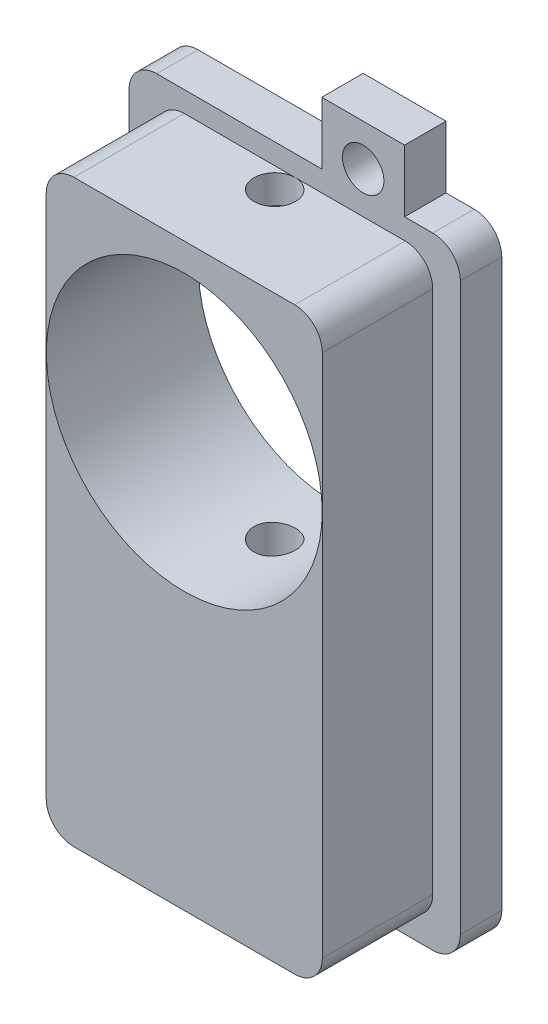
from build123d import *

# Parameters (mm, degrees)
SKETCH1_R           = 1.5
BOSS_EXTRUDE1_DEPTH = 3
FILLET1_R           = 2
SKETCH3_W           = 20
SKETCH3_H           = 42
BOSS_EXTRUDE2_DEPTH = 8
FILLET2_R           = 2
SKETCH4_R           = 9.99
CUT_EXTRUDE1_DEPTH  = 12
SKETCH5_R           = 1.5
CUT_EXTRUDE2_DEPTH  = 49


with BuildPart() as part:
    # Sketch1 → Boss-Extrude1 (new body)
    with BuildSketch(Plane.XY):
        Polygon((12, 22.5), (7.96, 22.5), (7.96, 27), (1.96, 27), (1.96, 22.5), (-12, 22.5), (-12, -22.5), (-7.96, -22.5), (-7.96, -27), (-1.96, -27), (-1.96, -22.5), (12, -22.5), align=None)
        with Locations((4.96, 24)):
            Circle(SKETCH1_R, mode=Mode.SUBTRACT)
        with Locations((-4.96, -24)):
            Circle(SKETCH1_R, mode=Mode.SUBTRACT)
    extrude(amount=BOSS_EXTRUDE1_DEPTH)

    # Fillet1
    fillet1_edges = [part.edges().sort_by_distance(p)[0] for p in [
        (-12, 22.5, 1.5),
        (12, 22.5, 1.5),
        (12, -22.5, 1.5),
        (-12, -22.5, 1.5),
    ]]
    fillet(fillet1_edges, radius=FILLET1_R)

    # Sketch3 → Boss-Extrude2 (add)
    with BuildSketch(Plane.XY.offset(3)):
        Rectangle(SKETCH3_W, SKETCH3_H)
    extrude(amount=BOSS_EXTRUDE2_DEPTH)

    # Fillet2
    fillet2_edges = [part.edges().sort_by_distance(p)[0] for p in [
        (-10, 21, 7),
        (-10, -21, 7),
        (10, -21, 7),
        (10, 21, 7),
    ]]
    fillet(fillet2_edges, radius=FILLET2_R)

    # Sketch4 → Cut-Extrude1 (cut, through all)
    with BuildSketch(Plane.XY.offset(11)):
        with Locations((0, 9)):
            Circle(SKETCH4_R)
    extrude(amount=-CUT_EXTRUDE1_DEPTH, mode=Mode.SUBTRACT)

    # Sketch5 → Cut-Extrude2 (cut, through all)
    with BuildSketch(Plane(origin=(0, 21, 0), x_dir=(1, 0, 0), z_dir=(0, 1, 0))):
        with Locations((0.05, -4.5)):
            Circle(SKETCH5_R)
    extrude(amount=-CUT_EXTRUDE2_DEPTH, mode=Mode.SUBTRACT)


solid = part.part
